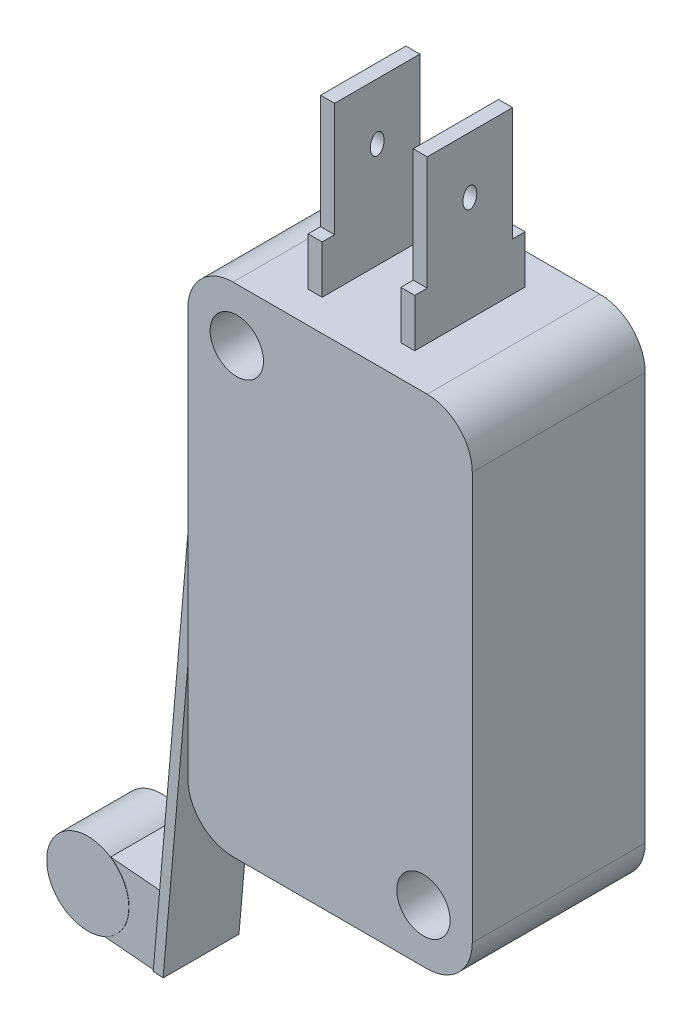
from build123d import *

# Parameters (mm, degrees)
BOSS_EXTRUDE1_DEPTH = 4.8641
SKETCH2_RX          = 0.5842
SKETCH2_RY          = 0.387956749
BOSS_EXTRUDE2_DEPTH = 0.7874
SKETCH4_RX          = 0.5842
SKETCH4_RY          = 0.387956749
BOSS_EXTRUDE3_DEPTH = 0.7874
BOSS_EXTRUDE5_DEPTH = 2.1336
BOSS_EXTRUDE6_DEPTH = 2.0574
BOSS_EXTRUDE7_DEPTH = 2.0701
SKETCH6_R           = 1.5
CUT_EXTRUDE1_DEPTH  = 33.419663703


with BuildPart() as part:
    # Sketch1 → Boss-Extrude1 (new, symmetric)
    with BuildSketch(Plane.XY):
        with BuildLine():
            Line((5.46, -14), (-5.46, -14))
            ThreePointArc((-5.46, -14), (-7.256051224, -13.256051224), (-8, -11.46))
            Line((-8, -11.46), (-8, 11.46))
            ThreePointArc((-8, 11.46), (-7.256051224, 13.256051224), (-5.46, 14))
            Line((-5.46, 14), (5.46, 14))
            ThreePointArc((5.46, 14), (7.256051224, 13.256051224), (8, 11.46))
            Line((8, 11.46), (8, -11.46))
            ThreePointArc((8, -11.46), (7.256051224, -13.256051224), (5.46, -14))
        make_face()
    extrude(amount=BOSS_EXTRUDE1_DEPTH, both=True)

    # Sketch2 → Boss-Extrude2 (add)
    with BuildSketch(Plane(origin=(3, 0, 0), x_dir=(0, 0, -1), z_dir=(1, 0, 0))):
        Polygon((-3.1, 14), (-3.1, 16.7), (-2.4, 16.7), (-2.4, 23.1), (2.4, 23.1), (2.4, 16.7), (3.1, 16.7), (3.1, 14), align=None)
        with Locations(Location((0, 19.925), (0, 0, -90))):
            Ellipse(SKETCH2_RX, SKETCH2_RY, mode=Mode.SUBTRACT)
    extrude(amount=-BOSS_EXTRUDE2_DEPTH)

    # Sketch4 → Boss-Extrude3 (add)
    with BuildSketch(Plane(origin=(-3, 0, 0), x_dir=(0, 0, -1), z_dir=(1, 0, 0))):
        Polygon((2.4, 16.7), (2.4, 23.1), (-2.4, 23.1), (-2.4, 16.7), (-3.1, 16.7), (-3.1, 14), (3.1, 14), (3.1, 16.7), align=None)
        with Locations(Location((0, 19.925), (0, 0, -90))):
            Ellipse(SKETCH4_RX, SKETCH4_RY, mode=Mode.SUBTRACT)
    extrude(amount=BOSS_EXTRUDE3_DEPTH)

    # Sketch5 → Boss-Extrude5 (add, symmetric)
    with BuildSketch(Plane.XY):
        Polygon((-8, 2.7732), (-10.29004586, 2.7732), (-12.680902195, -24.554412958), (-12.124228598, -24.603115587), (-9.778, 2.2144), (-8, 2.2144), align=None)
    extrude(amount=BOSS_EXTRUDE5_DEPTH, both=True)

    # Sketch5_6 → Boss-Extrude6 (add, symmetric)
    with BuildSketch(Plane.XY):
        with BuildLine():
            Line((-12.680902195, -24.554412958), (-12.326701257, -20.505877705))
            Line((-12.326701257, -20.505877705), (-15.151301123, -20.258757238))
            ThreePointArc((-15.151301123, -20.258757238), (-14.390077946, -21.092333666), (-14.114420252, -22.187013172))
            ThreePointArc((-14.114420252, -22.187013172), (-14.493232166, -23.454953726), (-15.505502062, -24.307292491))
            Line((-15.505502062, -24.307292491), (-12.680902195, -24.554412958))
        make_face()
    extrude(amount=BOSS_EXTRUDE6_DEPTH, both=True)

    # Sketch5_7 → Boss-Extrude7 (add, symmetric)
    with BuildSketch(Plane.XY):
        with BuildLine():
            ThreePointArc((-14.114420252, -22.187013172), (-14.390077946, -21.092333666), (-15.151301123, -20.258757238))
            ThreePointArc((-15.151301123, -20.258757238), (-18.728424677, -21.985561389), (-15.505502062, -24.307292491))
            ThreePointArc((-15.505502062, -24.307292491), (-14.493232166, -23.454953726), (-14.114420252, -22.187013172))
        make_face()
    extrude(amount=BOSS_EXTRUDE7_DEPTH, both=True)

    # Sketch6 → Cut-Extrude1 (cut, through all)
    with BuildSketch(Plane.XY.offset(4.8641)):
        with Locations((-5.25, 11)):
            Circle(SKETCH6_R)
        with Locations((5.25, -11)):
            Circle(SKETCH6_R)
    extrude(amount=-CUT_EXTRUDE1_DEPTH, mode=Mode.SUBTRACT)


solid = part.part
